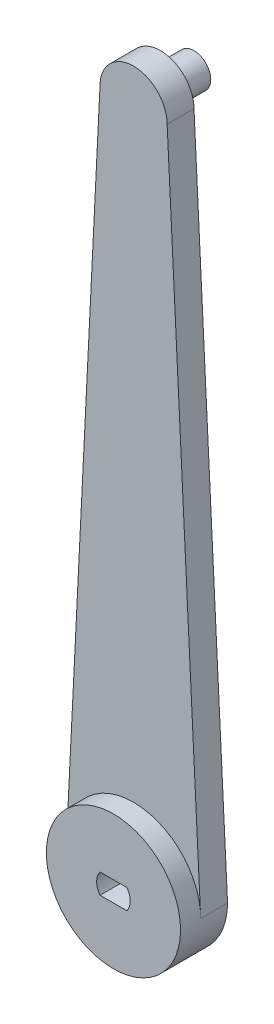
from build123d import *

# Parameters (mm, degrees)
BOSS_EXTRUDE1_DEPTH = 4
SKETCH4_R           = 10
BOSS_EXTRUDE2_DEPTH = 3
CUT_EXTRUDE3_DEPTH  = 11
SKETCH5_R           = 2.5
BOSS_EXTRUDE4_DEPTH = 9


with BuildPart() as part:
    # Sketch3 → Boss-Extrude1 (new body)
    with BuildSketch(Plane.XY):
        with BuildLine():
            Line((-10, 0), (-5, 100))
            ThreePointArc((-5, 100), (0, 105), (5, 100))
            Line((5, 100), (10, 0))
            ThreePointArc((10, 0), (0, -10), (-10, 0))
        make_face()
    extrude(amount=BOSS_EXTRUDE1_DEPTH)

    # Sketch4 → Boss-Extrude2 (add)
    with BuildSketch(Plane.XY.offset(4)):
        Circle(SKETCH4_R)
    extrude(amount=BOSS_EXTRUDE2_DEPTH)

    # Sketch2 → Cut-Extrude3 (cut)
    with BuildSketch(Plane.XY):
        with BuildLine():
            Line((-2, -1.5), (2, -1.5))
            ThreePointArc((2, -1.5), (2.5, 0), (2, 1.5))
            Line((2, 1.5), (-2, 1.5))
            ThreePointArc((-2, 1.5), (-2.5, 0), (-2, -1.5))
        make_face()
    extrude(amount=CUT_EXTRUDE3_DEPTH, mode=Mode.SUBTRACT)

    # Sketch5 → Boss-Extrude4 (add)
    with BuildSketch(Plane.XY.offset(4)):
        with Locations((0, 100)):
            Circle(SKETCH5_R)
    extrude(amount=-BOSS_EXTRUDE4_DEPTH)


solid = part.part
